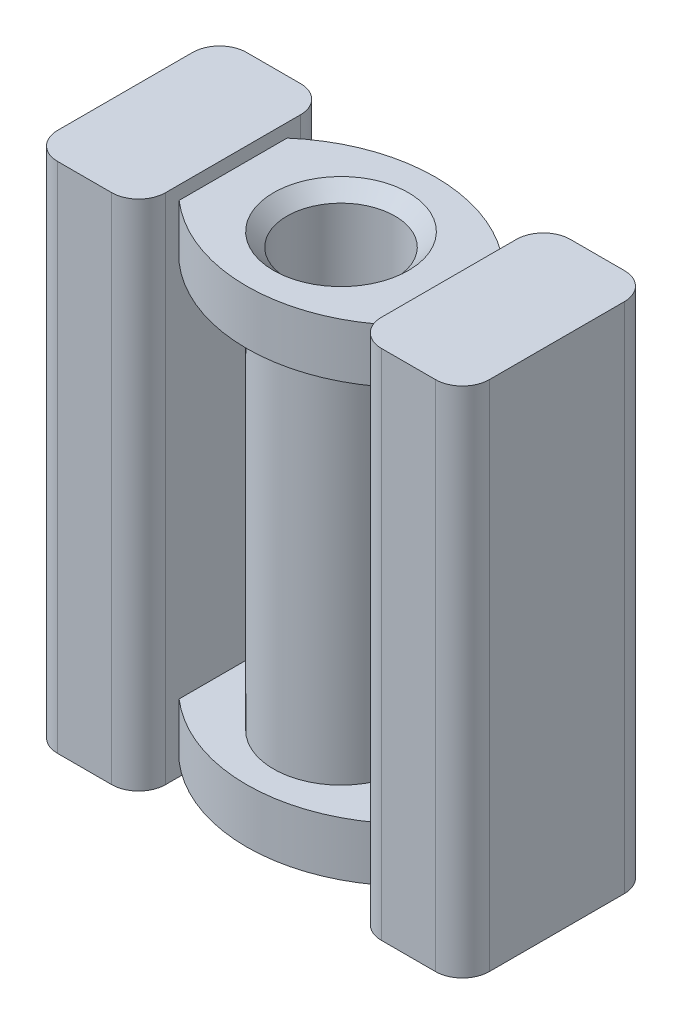
from build123d import *

# Parameters (mm, degrees)
SKETCH1_R             = 1.25
BOSS_EXTRUDE1_DEPTH   = 4.5
BOSS_EXTRUDE2_START   = -3.5
BOSS_EXTRUDE2_DEPTH   = 1
SKETCH3_W             = 2
SKETCH3_H             = 3.5
BOSS_EXTRUDE3_DEPTH   = 4.75
FILLET2_R             = 0.5
F_2_0MM_DOWEL_HOLE1_D = 2
CHAMFER1_SIZE         = 0.25


with BuildPart() as part:
    # Sketch1 → Boss-Extrude1 (new body, symmetric)
    with BuildSketch(Plane(origin=(0, 0, 0), x_dir=(1, 0, 0), z_dir=(0, 1, 0))):
        Circle(SKETCH1_R)
    extrude(amount=BOSS_EXTRUDE1_DEPTH, both=True)

    # Sketch2 → Boss-Extrude2 (add)
    with BuildSketch(Plane(origin=(0, 0, 0), x_dir=(1, 0, 0), z_dir=(0, 1, 0)).offset(BOSS_EXTRUDE2_START)):
        with BuildLine():
            Line((-2, -1), (-2, 1))
            ThreePointArc((-2, 1), (0, 1.75), (2, 1))
            Line((2, 1), (2, -1))
            ThreePointArc((2, -1), (0, -1.75), (-2, -1))
        make_face()
    boss_extrude2 = extrude(amount=-BOSS_EXTRUDE2_DEPTH)

    # Mirror2: Boss-Extrude2 across plane
    add(boss_extrude2.mirror(Plane.ZX))

    # Sketch3 → Boss-Extrude3 (add, symmetric)
    with BuildSketch(Plane(origin=(0, 0, 0), x_dir=(1, 0, 0), z_dir=(0, 1, 0))):
        with Locations((-3, 0)):
            Rectangle(SKETCH3_W, SKETCH3_H)
    boss_extrude3 = extrude(amount=BOSS_EXTRUDE3_DEPTH, both=True)

    # Mirror3: Boss-Extrude3 across plane
    add(boss_extrude3.mirror(Plane(origin=(0, 0, 0), x_dir=(0, 0, 1), z_dir=(1, 0, 0))))

    # Fillet2
    fillet2_edges = [part.edges().sort_by_distance(p)[0] for p in [
        (-2, 0, 1.75),
        (-4, 0, -1.75),
        (-4, 0, 1.75),
        (-2, 0, -1.75),
        (2, 0, -1.75),
        (4, 0, 1.75),
        (4, 0, -1.75),
        (2, 0, 1.75),
    ]]
    fillet(fillet2_edges, radius=FILLET2_R)

    # Ø2.0mm Dowel Hole1 (through all)
    with Locations(Plane(origin=(0, 4.5, 0), x_dir=(1, 0, 0), z_dir=(0, 1, 0))):
        with Locations((0, 0)):
            Hole(F_2_0MM_DOWEL_HOLE1_D / 2)

    # Chamfer1
    chamfer1_edges = [part.edges().sort_by_distance(p)[0] for p in [
        (1, -4.5, 0),
        (1, 4.5, 0),
    ]]
    chamfer(chamfer1_edges, length=CHAMFER1_SIZE)


solid = part.part
